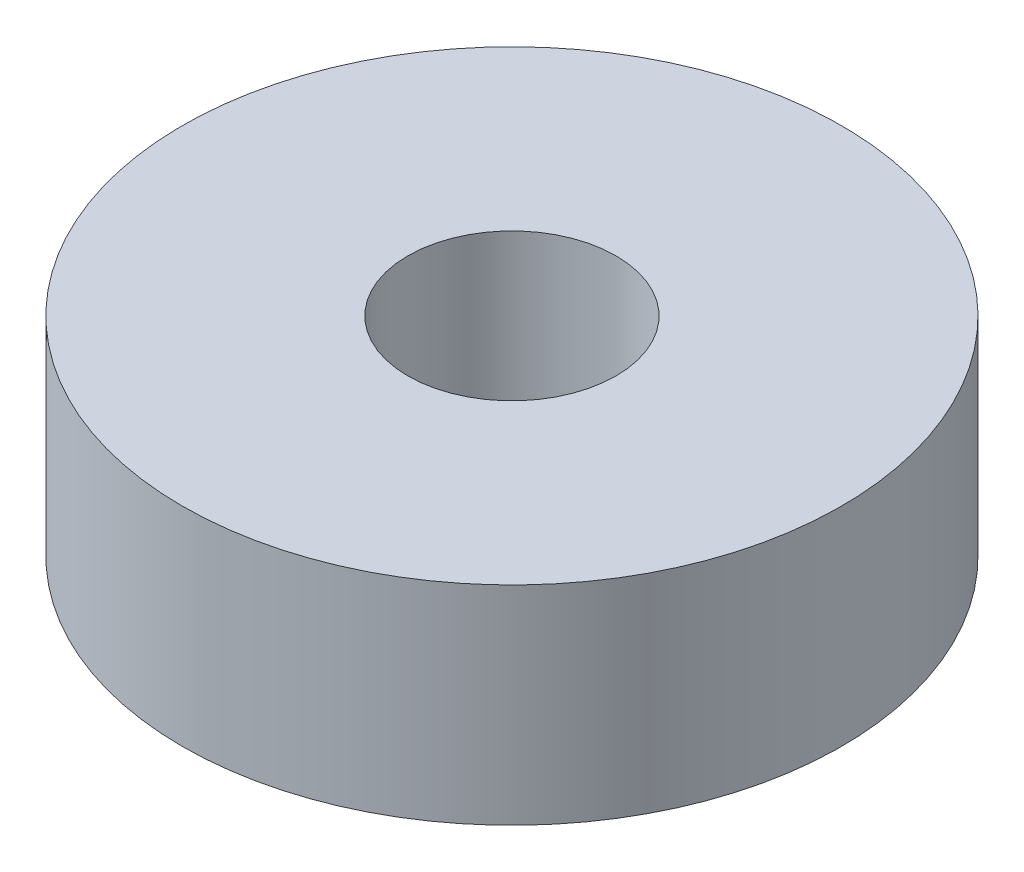
from build123d import *

# Parameters (mm, degrees)
SKETCH1_R           = 9.5
SKETCH1_R_2         = 3
BOSS_EXTRUDE1_DEPTH = 6


with BuildPart() as part:
    # Sketch1 → Boss-Extrude1 (new body)
    with BuildSketch(Plane(origin=(0, 0, 0), x_dir=(1, 0, 0), z_dir=(0, 1, 0))):
        Circle(SKETCH1_R)
        Circle(SKETCH1_R_2, mode=Mode.SUBTRACT)
    extrude(amount=BOSS_EXTRUDE1_DEPTH)


solid = part.part
